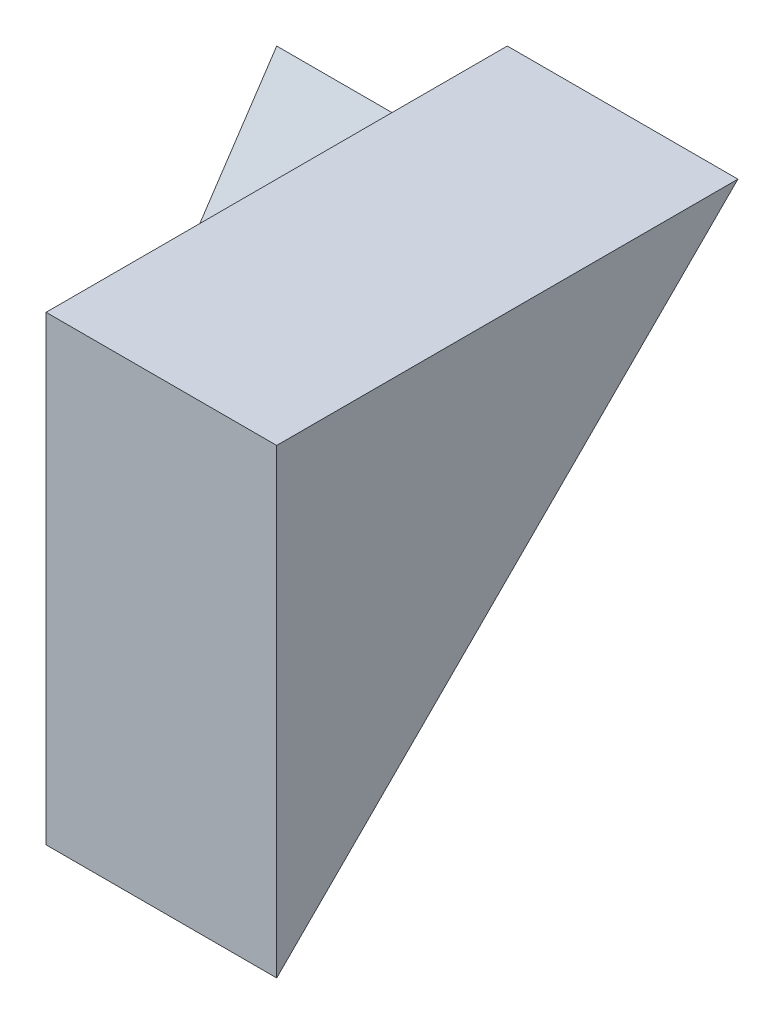
from build123d import *

# Parameters (mm, degrees)
SKETCH1_W           = 4
SKETCH1_H           = 4
BOSS_EXTRUDE1_DEPTH = 2
SKETCH2_W           = 2
SKETCH2_H           = 3
BOSS_EXTRUDE2_DEPTH = 2
CUT_EXTRUDE1_DEPTH  = 2
CUT_EXTRUDE2_DEPTH  = 2


with BuildPart() as part:
    # Sketch1 → Boss-Extrude1 (new body)
    with BuildSketch(Plane(origin=(0, 0, 0), x_dir=(0, 0, -1), z_dir=(1, 0, 0))):
        with Locations((2, 2)):
            Rectangle(SKETCH1_W, SKETCH1_H)
    extrude(amount=BOSS_EXTRUDE1_DEPTH)

    # Sketch2 → Boss-Extrude2 (add)
    with BuildSketch(Plane.ZY):
        with Locations((-3, 1.5)):
            Rectangle(SKETCH2_W, SKETCH2_H)
    extrude(amount=BOSS_EXTRUDE2_DEPTH)

    # Sketch3 → Cut-Extrude1 (cut)
    with BuildSketch(Plane.ZY.offset(2)):
        Polygon((-4, 3), (-2, 3), (-2, 0), align=None)
    extrude(amount=-CUT_EXTRUDE1_DEPTH, mode=Mode.SUBTRACT)

    # Sketch4 → Cut-Extrude2 (cut)
    with BuildSketch(Plane(origin=(2, 0, 0), x_dir=(0, 0, -1), z_dir=(1, 0, 0))):
        Polygon((4, 4), (0, 0), (4, 0), align=None)
    extrude(amount=-CUT_EXTRUDE2_DEPTH, mode=Mode.SUBTRACT)


solid = part.part
